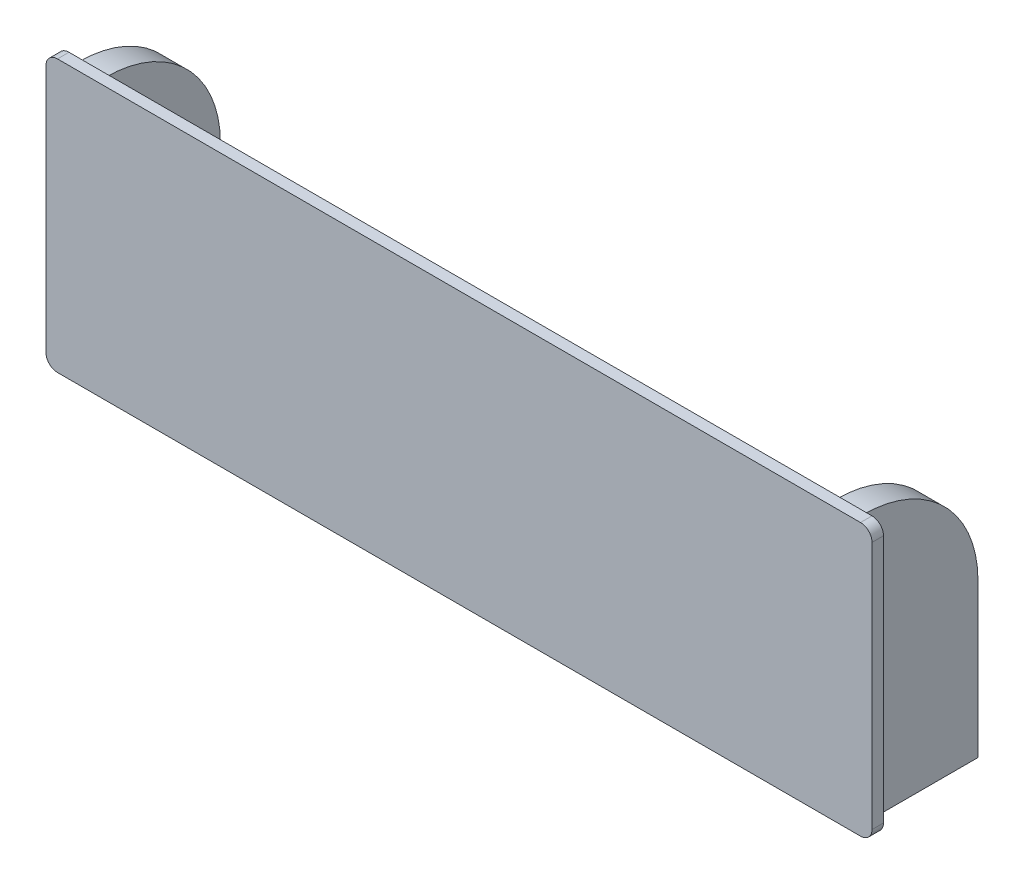
from build123d import *

# Parameters (mm, degrees)
SKETCH_1_W        = 7
SKETCH_1_H        = 70
EXTRUDE_1_DEPTH   = 30.15
EXTRUDE_1_2_DEPTH = 30.15
FILLET_1_R        = 30
FILLET_2_R        = 30
SKETCH_2_W        = 215.9
SKETCH_2_H        = 71
EXTRUDE_2_DEPTH   = 3
FILLET_3_R        = 3


with BuildPart() as part:
    # 스케치1 → 보스-돌출1 (new body)
    with BuildSketch(Plane.XY):
        with Locations((3.5, 35)):
            Rectangle(SKETCH_1_W, SKETCH_1_H)
    extrude(amount=EXTRUDE_1_DEPTH)

    # 필렛2
    fillet_2_edges = [part.edges().sort_by_distance(p)[0] for p in [
        (3.5, 70, 0),
    ]]
    fillet(fillet_2_edges, radius=FILLET_2_R)



with BuildPart() as body_2:
    # 스케치1 → Extrude 1 2 (new body)
    with BuildSketch(Plane.XY):
        with Locations((201.5, 35)):
            Rectangle(SKETCH_1_W, SKETCH_1_H)
    extrude(amount=EXTRUDE_1_2_DEPTH)

    # 필렛1
    fillet_1_edges = [body_2.edges().sort_by_distance(p)[0] for p in [
        (201.5, 70, 0),
    ]]
    fillet(fillet_1_edges, radius=FILLET_1_R)


with BuildPart() as part_1:
    add(part.part)

    add(body_2.part)  # 보스-돌출2 merges body 2
    # 스케치2 → 보스-돌출2 (add)
    with BuildSketch(Plane.XY.offset(30.15)):
        with Locations((102.5, 35.5)):
            Rectangle(SKETCH_2_W, SKETCH_2_H)
    extrude(amount=EXTRUDE_2_DEPTH)

    # 필렛3
    fillet_3_edges = [part_1.edges().sort_by_distance(p)[0] for p in [
        (210.45, 0, 31.65),
        (210.45, 71, 31.65),
        (-5.45, 71, 31.65),
        (-5.45, 0, 31.65),
    ]]
    fillet(fillet_3_edges, radius=FILLET_3_R)


solid = part_1.part
